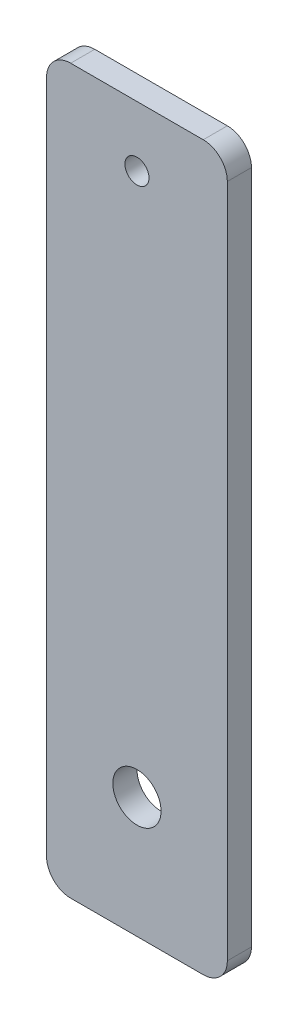
from build123d import *

# Parameters (mm, degrees)
SKETCH1_W           = 15
SKETCH1_H           = 60
SKETCH1_R           = 2
SKETCH1_R_2         = 1
BOSS_EXTRUDE1_DEPTH = 2
FILLET1_R           = 2


with BuildPart() as part:
    # Sketch1 → Boss-Extrude1 (new body)
    with BuildSketch(Plane.XY):
        Rectangle(SKETCH1_W, SKETCH1_H)
        with Locations((0, -20)):
            Circle(SKETCH1_R, mode=Mode.SUBTRACT)
        with Locations((0, 25)):
            Circle(SKETCH1_R_2, mode=Mode.SUBTRACT)
    extrude(amount=BOSS_EXTRUDE1_DEPTH)

    # Fillet1
    fillet1_edges = [part.edges().sort_by_distance(p)[0] for p in [
        (7.5, -30, 1),
        (-7.5, -30, 1),
        (-7.5, 30, 1),
        (7.5, 30, 1),
    ]]
    fillet(fillet1_edges, radius=FILLET1_R)


solid = part.part
